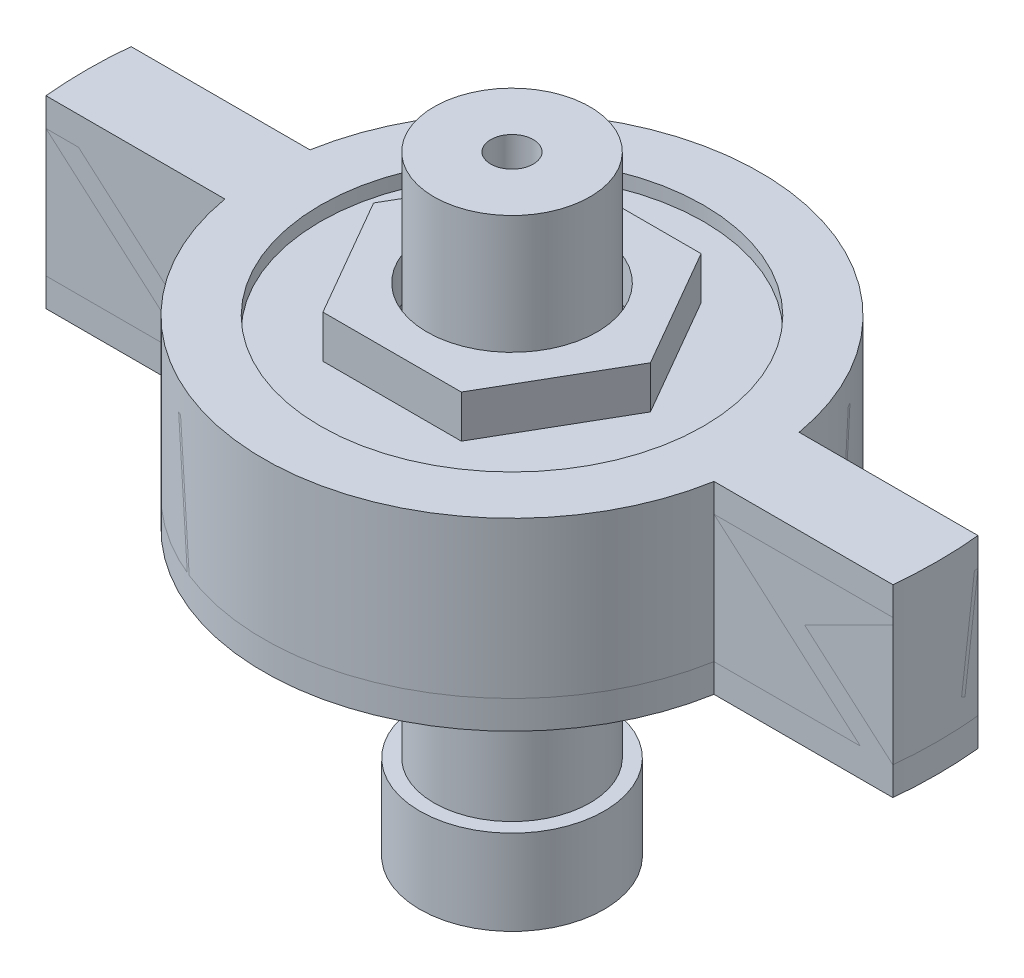
from build123d import *

# Parameters (mm, degrees)
SKETCH2_R                = 5.5
BOSS_EXTRUDE1_DEPTH      = 32
SKETCH2_3_R              = 6.5
SKETCH2_3_R_2            = 5.5
BOSS_EXTRUDE2_DEPTH      = 6
SKETCH5_R                = 5.5
SKETCH5_R_2              = 3.95
CUT_EXTRUDE1_DEPTH       = 16
SKETCH6_R                = 13.5
SKETCH6_R_2              = 11
BOSS_EXTRUDE4_DEPTH      = 10
SKETCH7_R                = 11.05
SKETCH7_R_2              = 7.5
BOSS_EXTRUDE5_DEPTH      = 3
SKETCH9_R                = 17.5
SKETCH9_R_2              = 13.5
BOSS_EXTRUDE6_DEPTH      = 11
SKETCH10_R               = 6
BOSS_EXTRUDE7_DEPTH      = 3
CHAMFER2_SIZE            = 2
CHAMFER2_SIZE2           = 3.464101615
BOSS_EXTRUDE8_DEPTH      = 11
SKETCH12_R               = 5.5
SKETCH12_R_2             = 4
BOSS_EXTRUDE9_DEPTH      = 5
BOSS_EXTRUDE9_DEPTH_BACK = 9.2
SKETCH16_R               = 4
BOSS_EXTRUDE10_DEPTH     = 2.9
SKETCH17_R               = 1.5
CUT_EXTRUDE2_DEPTH       = 10


with BuildPart() as part:
    # Sketch2 → Boss-Extrude1 (new body)
    with BuildSketch(Plane(origin=(0, 0, 0), x_dir=(1, 0, 0), z_dir=(0, 1, 0))):
        with Locations(Location((0, 0, 0), (0, 0, 270))):
            Circle(SKETCH2_R)
    extrude(amount=BOSS_EXTRUDE1_DEPTH)

    # Sketch5 → Cut-Extrude1 (cut)
    with BuildSketch(Plane(origin=(0, 32, 0), x_dir=(1, 0, 0), z_dir=(0, 1, 0))):
        with Locations(Location((0, 0, 0), (0, 0, 270))):
            Circle(SKETCH5_R)
        with Locations(Location((0, 0, 0), (0, 0, 270))):
            Circle(SKETCH5_R_2, mode=Mode.SUBTRACT)
    extrude(amount=-CUT_EXTRUDE1_DEPTH, mode=Mode.SUBTRACT)


with BuildPart() as body_2:
    # Sketch2_3 → Boss-Extrude2 (new body)
    with BuildSketch(Plane(origin=(0, 0, 0), x_dir=(1, 0, 0), z_dir=(0, 1, 0))):
        with Locations(Location((0, 0, 0), (0, 0, 270))):
            Circle(SKETCH2_3_R)
        with Locations(Location((0, 0, 0), (0, 0, 270))):
            Circle(SKETCH2_3_R_2, mode=Mode.SUBTRACT)
        with Locations(Location((0, 0, 0), (0, 0, 270))):
            Circle(SKETCH2_3_R_2)
    extrude(amount=-BOSS_EXTRUDE2_DEPTH)


with BuildPart() as body_3:
    # Sketch6 → Boss-Extrude4 (new body)
    with BuildSketch(Plane(origin=(0, 16, 0), x_dir=(1, 0, 0), z_dir=(0, 1, 0))):
        with Locations(Location((0, 0, 0), (0, 0, 270))):
            Circle(SKETCH6_R)
        with Locations(Location((0, 0, 0), (0, 0, 270))):
            Circle(SKETCH6_R_2, mode=Mode.SUBTRACT)
    extrude(amount=BOSS_EXTRUDE4_DEPTH)

    # Sketch7 → Boss-Extrude5 (add)
    with BuildSketch(Plane(origin=(0, 26, 0), x_dir=(1, 0, 0), z_dir=(0, 1, 0))):
        Circle(SKETCH7_R)
        with Locations(Location((0, 0, 0), (0, 0, 270))):
            Circle(SKETCH7_R_2, mode=Mode.SUBTRACT)
    extrude(amount=-BOSS_EXTRUDE5_DEPTH)

    # Sketch9 → Boss-Extrude6 (add)
    with BuildSketch(Plane.XZ.offset(-16)):
        with Locations(Location((0, 0, 0), (0, 0, 270))):
            Circle(SKETCH9_R)
        with Locations(Location((0, 0, 0), (0, 0, 270))):
            Circle(SKETCH9_R_2, mode=Mode.SUBTRACT)
    extrude(amount=-BOSS_EXTRUDE6_DEPTH)

    # Sketch10 → Boss-Extrude7 (add)
    with BuildSketch(Plane(origin=(0, 26, 0), x_dir=(1, 0, 0), z_dir=(0, 1, 0))):
        Polygon((9.757219549, 0), (4.878609775, 8.45), (-4.878609775, 8.45), (-9.757219549, 0), (-4.878609775, -8.45), (4.878609775, -8.45), align=None)
        with Locations(Location((0, 0, 0), (0, 0, 270))):
            Circle(SKETCH10_R, mode=Mode.SUBTRACT)
    extrude(amount=BOSS_EXTRUDE7_DEPTH)

    # Chamfer2
    chamfer2_edges = [body_3.edges().sort_by_distance(p)[0] for p in [
        (0, 23, -7.5),
    ]]
    chamfer2_side = [body_3.faces().sort_by_distance(p)[0] for p in [
        (0, 24.5, -7.5),
    ]]
    chamfer(chamfer2_edges, length=CHAMFER2_SIZE, length2=CHAMFER2_SIZE2, reference=chamfer2_side[0])

    # Sketch11 → Boss-Extrude8 (add)
    with BuildSketch(Plane.XZ.offset(-16)):
        with BuildLine():
            ThreePointArc((17.24093965, 3), (17.435114623, 1.505582301), (17.5, 0))
            Line((17.5, 0), (30, 0))
            ThreePointArc((30, 0), (29.962382193, 1.501883252), (29.849623113, 3))
            Line((29.849623113, 3), (17.24093965, 3))
        make_face()
        with BuildLine():
            Line((-30, 0), (-17.5, 0))
            ThreePointArc((-17.5, 0), (-17.435114623, 1.505582301), (-17.24093965, 3))
            Line((-17.24093965, 3), (-29.849623113, 3))
            ThreePointArc((-29.849623113, 3), (-29.962382193, 1.501883252), (-30, 0))
        make_face()
        with BuildLine():
            Line((30, 0), (17.5, 0))
            ThreePointArc((17.5, 0), (17.435114623, -1.505582301), (17.24093965, -3))
            Line((17.24093965, -3), (29.849623113, -3))
            ThreePointArc((29.849623113, -3), (29.962382193, -1.501883252), (30, 0))
        make_face()
        with BuildLine():
            ThreePointArc((-17.24093965, -3), (-17.435114623, -1.505582301), (-17.5, 0))
            Line((-17.5, 0), (-30, 0))
            ThreePointArc((-30, 0), (-29.962382193, -1.501883252), (-29.849623113, -3))
            Line((-29.849623113, -3), (-17.24093965, -3))
        make_face()
    extrude(amount=-BOSS_EXTRUDE8_DEPTH)


with BuildPart() as body_4:
    # Sketch12 → Boss-Extrude9 (new, two sides)
    with BuildSketch(Plane(origin=(0, 32, 0), x_dir=(1, 0, 0), z_dir=(0, 1, 0))) as boss_extrude9_sk:
        with Locations(Location((0, 0, 0), (0, 0, 270))):
            Circle(SKETCH12_R)
        with Locations(Location((0, 0, 0), (0, 0, 270))):
            Circle(SKETCH12_R_2, mode=Mode.SUBTRACT)
    extrude(amount=BOSS_EXTRUDE9_DEPTH)
    extrude(boss_extrude9_sk.sketch, amount=-BOSS_EXTRUDE9_DEPTH_BACK)

    # Sketch16 → Boss-Extrude10 (add)
    with BuildSketch(Plane(origin=(0, 37, 0), x_dir=(1, 0, 0), z_dir=(0, 1, 0))):
        with Locations(Location((0, 0, 0), (0, 0, 270))):
            Circle(SKETCH16_R)
    extrude(amount=-BOSS_EXTRUDE10_DEPTH)


with BuildPart() as part_1:
    add(part.part)

    # Combine1: union body 2
    add(body_2.part)


with BuildPart() as body_4_2:
    # Mirror1: mirrored copy
    add(body_3.part.mirror(Plane.ZX.offset(20.5)))


with BuildPart() as cut_extrude2_tool:
    # Sketch17 → Cut-Extrude2 (new body)
    with BuildSketch(Plane(origin=(0, 37, 0), x_dir=(1, 0, 0), z_dir=(0, 1, 0))):
        with Locations(Location((0, 0, 0), (0, 0, 270))):
            Circle(SKETCH17_R)
    extrude(amount=-CUT_EXTRUDE2_DEPTH)


with BuildPart() as part_2:
    add(part_1.part)

    # Cut-Extrude2: cut by cut_extrude2_tool
    add(cut_extrude2_tool.part, mode=Mode.SUBTRACT)


with BuildPart() as body_4_1:
    add(body_4.part)

    # Cut-Extrude2: cut by cut_extrude2_tool
    add(cut_extrude2_tool.part, mode=Mode.SUBTRACT)


solid = Compound([body_3.part, body_4_2.part, part_2.part, body_4_1.part])
